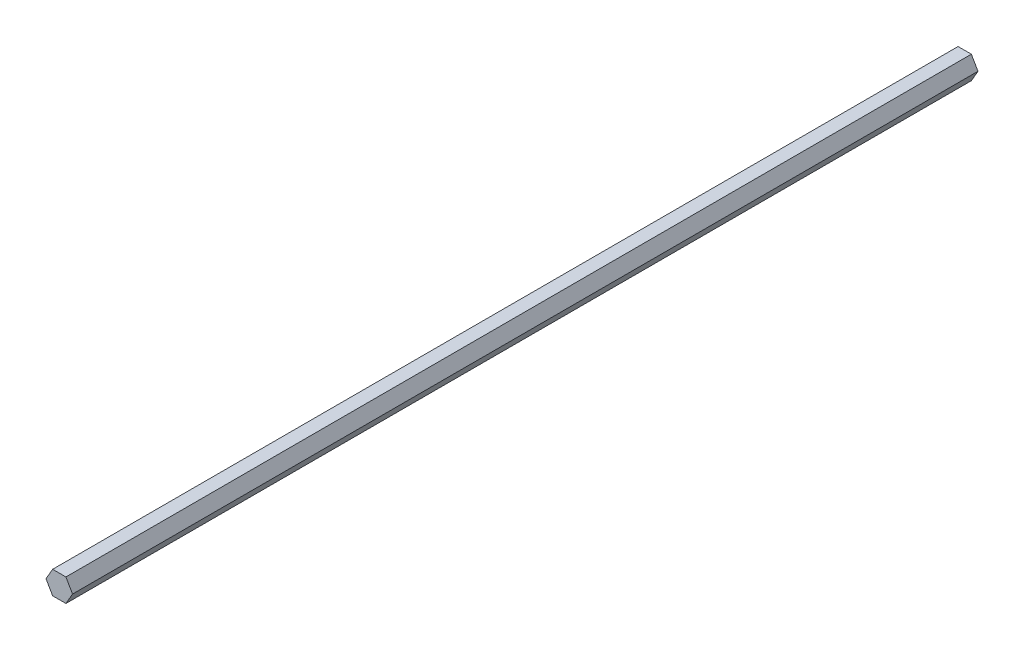
from build123d import *

# Parameters (mm, degrees)
BOSS_EXTRUDE1_DEPTH = 500


with BuildPart() as part:
    # Sketch1 → Boss-Extrude1 (new body)
    with BuildSketch(Plane.XY):
        Polygon((-3.665, 6.34796621), (-7.33, 0), (-3.665, -6.34796621), (3.665, -6.34796621), (7.33, 0), (3.665, 6.34796621), align=None)
    extrude(amount=BOSS_EXTRUDE1_DEPTH)


solid = part.part
